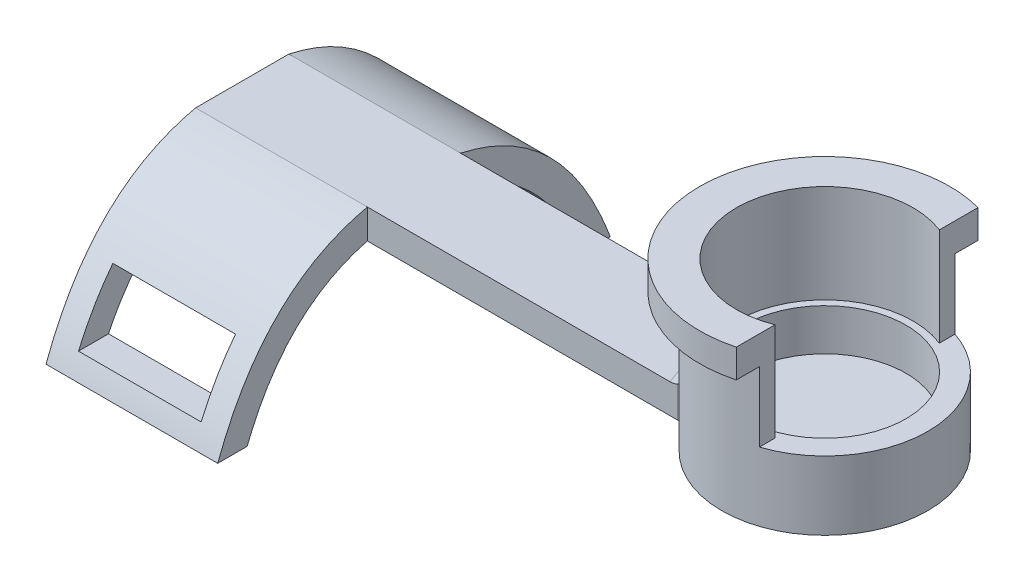
from build123d import *

# Parameters (mm, degrees)
F_0_1MM_FIT_FOR_POT_R   = 10.5
BOSS_EXTRUDE1_DEPTH     = 2.75
SKETCH4_R               = 10.5
SKETCH4_R_2             = 8.275
BOSS_EXTRUDE2_DEPTH     = 4.25
BOSS_EXTRUDE3_DEPTH     = 2
FILLET1_R               = 0.25
BOSS_EXTRUDE6_DEPTH     = 10
BOSS_EXTRUDE7_DEPTH     = 2.9
BOSS_EXTRUDE8_DEPTH     = 3
FILLET2_R               = 1.5
BOSS_EXTRUDE9_DEPTH     = 17.5
SKETCH12_W              = 12.5
SKETCH12_H              = 6
CUT_EXTRUDE2_DEPTH      = 67.52567968
CUT_EXTRUDE2_DEPTH_BACK = 67.52567968


with BuildPart() as part:
    # 0.1mm fit for pot → Boss-Extrude1 (new body)
    with BuildSketch(Plane(origin=(0, 0, 0), x_dir=(1, 0, 0), z_dir=(0, 1, 0))):
        with Locations(Location((0, 0, 0), (0, 0, 270))):
            Circle(F_0_1MM_FIT_FOR_POT_R)
    extrude(amount=BOSS_EXTRUDE1_DEPTH)

    # Sketch4 → Boss-Extrude2 (add)
    with BuildSketch(Plane(origin=(0, 2.75, 0), x_dir=(1, 0, 0), z_dir=(0, 1, 0))):
        with Locations(Location((0, 0, 0), (0, 0, 270))):
            Circle(SKETCH4_R)
        with Locations(Location((0, 0, 0), (0, 0, 270))):
            Circle(SKETCH4_R_2, mode=Mode.SUBTRACT)
    extrude(amount=BOSS_EXTRUDE2_DEPTH)

    # Sketch5 → Boss-Extrude3 (add)
    with BuildSketch(Plane(origin=(0, 2.75, 0), x_dir=(1, 0, 0), z_dir=(0, 1, 0))):
        with BuildLine():
            Line((-1, -8.214354813), (-1, -7.065799598))
            Line((-1, -7.065799598), (0.988059701, -7.065799598))
            Line((0.988059701, -7.065799598), (0.988059701, -8.215799598))
            ThreePointArc((0.988059701, -8.215799598), (-0.006013695, -8.274997815), (-1, -8.214354813))
        make_face()
    extrude(amount=BOSS_EXTRUDE3_DEPTH)

    # Fillet1
    fillet1_edges = [part.edges().sort_by_distance(p)[0] for p in [
        (0.988059701, 3.75, 7.065799598),
        (-1, 3.75, 7.065799598),
        (-0.005970149, 4.75, 7.065799598),
        (-1, 4.75, 7.640077205),
        (0.988059701, 4.75, 7.640799598),
    ]]
    fillet(fillet1_edges, radius=FILLET1_R)

    # Sketch7 → Boss-Extrude6 (add)
    with BuildSketch(Plane(origin=(0, 7, 0), x_dir=(1, 0, 0), z_dir=(0, 1, 0))):
        with BuildLine():
            Line((3.299602194, 9.968080325), (3.299602194, 8.373328213))
            ThreePointArc((3.299602194, 8.373328213), (-9, 0), (3.299602194, -8.373328213))
            Line((3.299602194, -8.373328213), (3.299602194, -9.968080325))
            ThreePointArc((3.299602194, -9.968080325), (-10.5, 0), (3.299602194, 9.968080325))
        make_face()
    extrude(amount=BOSS_EXTRUDE6_DEPTH)

    # Sketch8 → Boss-Extrude7 (add)
    with BuildSketch(Plane(origin=(0, 17, 0), x_dir=(1, 0, 0), z_dir=(0, 1, 0))):
        with BuildLine():
            Line((3.299602194, 12.315645552), (3.299602194, 9.968080325))
            ThreePointArc((3.299602194, 9.968080325), (-10.5, 0), (3.299602194, -9.968080325))
            Line((3.299602194, -9.968080325), (3.299602194, -12.315645552))
            ThreePointArc((3.299602194, -12.315645552), (-12.75, 0), (3.299602194, 12.315645552))
        make_face()
    extrude(amount=-BOSS_EXTRUDE7_DEPTH)

    # Sketch9 → Boss-Extrude8 (add)
    with BuildSketch(Plane.XZ):
        with BuildLine():
            Line((-9.3641604, 4.75), (-59.3641604, 4.75))
            Line((-59.3641604, 4.75), (-59.3641604, -4.75))
            Line((-59.3641604, -4.75), (-9.3641604, -4.75))
            ThreePointArc((-9.3641604, -4.75), (-10.5, 0), (-9.3641604, 4.75))
        make_face()
    extrude(amount=-BOSS_EXTRUDE8_DEPTH)

    # Fillet2
    fillet2_edges = [part.edges().sort_by_distance(p)[0] for p in [
        (-10.5, 3, 0),
        (-9.3641604, 1.5, 4.75),
        (-9.3641604, 1.5, -4.75),
    ]]
    fillet(fillet2_edges, radius=FILLET2_R)

    # Sketch10 → Boss-Extrude9 (add)
    with BuildSketch(Plane.ZY.offset(59.3641604)):
        with BuildLine():
            Line((-20, -12), (-17, -12))
            add(Edge.make_bspline(
                [(-17, -12), (-13.13473835, -2.13897718), (-4.75, 0)],
                knots=[0, 0, 0, 0.391543848, 0.391543848, 0.391543848], degree=2))
            Line((-4.75, 0), (4.75, 0))
            add(Edge.make_bspline(
                [(4.75, 0), (13.134738349, -2.13897718), (17, -12)],
                knots=[0.608456152, 0.608456152, 0.608456152, 1, 1, 1], degree=2))
            Line((17, -12), (20, -12))
            add(Edge.make_bspline(
                [(4.75, 3), (15.273777711, 0.693481354), (20, -12)],
                knots=[0.590854454, 0.590854454, 0.590854454, 1, 1, 1], degree=2))
            Line((4.75, 3), (-4.75, 3))
            add(Edge.make_bspline(
                [(-20, -12), (-15.273777711, 0.693481354), (-4.75, 3)],
                knots=[0, 0, 0, 0.409145546, 0.409145546, 0.409145546], degree=2))
        make_face()
    extrude(amount=-BOSS_EXTRUDE9_DEPTH)

    # Sketch12 → Cut-Extrude2 (cut, two sides)
    with BuildSketch(Plane(origin=(0, 0, -4.75), x_dir=(-1, 0, 0), z_dir=(0, 0, -1))) as cut_extrude2_sk:
        with Locations((50.6141604, -7)):
            Rectangle(SKETCH12_W, SKETCH12_H)
    extrude(amount=CUT_EXTRUDE2_DEPTH, mode=Mode.SUBTRACT)
    extrude(cut_extrude2_sk.sketch, amount=-CUT_EXTRUDE2_DEPTH_BACK, mode=Mode.SUBTRACT)


solid = part.part
